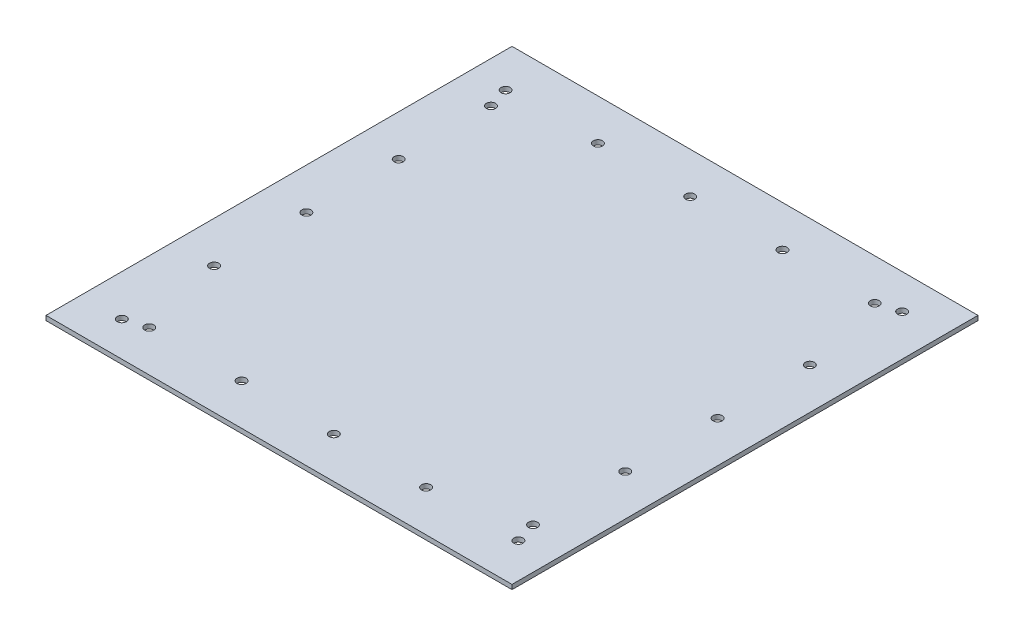
from build123d import *

# Parameters (mm, degrees)
SKETCH1_W           = 510
SKETCH1_H           = 510
BOSS_EXTRUDE1_DEPTH = 5
SKETCH3_R           = 5
CUT_EXTRUDE1_DEPTH  = 6


with BuildPart() as part:
    # Sketch1 → Boss-Extrude1 (new body)
    with BuildSketch(Plane(origin=(0, 0, 0), x_dir=(1, 0, 0), z_dir=(0, 1, 0))):
        Rectangle(SKETCH1_W, SKETCH1_H)
    extrude(amount=BOSS_EXTRUDE1_DEPTH)

    # Sketch3 → Cut-Extrude1 (cut, through all)
    with BuildSketch(Plane.XZ):
        with Locations((217, 210)):
            Circle(SKETCH3_R)
        with Locations((116, 210)):
            Circle(SKETCH3_R)
        with Locations((15, 210)):
            Circle(SKETCH3_R)
        with Locations((-86, 210)):
            Circle(SKETCH3_R)
        with Locations((-187, 210)):
            Circle(SKETCH3_R)
        with Locations((-210, 217)):
            Circle(SKETCH3_R)
        with Locations((-210, 116)):
            Circle(SKETCH3_R)
        with Locations((-210, 15)):
            Circle(SKETCH3_R)
        with Locations((-210, -86)):
            Circle(SKETCH3_R)
        with Locations((-210, -187)):
            Circle(SKETCH3_R)
        with Locations((-217, -210)):
            Circle(SKETCH3_R)
        with Locations((-116, -210)):
            Circle(SKETCH3_R)
        with Locations((-15, -210)):
            Circle(SKETCH3_R)
        with Locations((86, -210)):
            Circle(SKETCH3_R)
        with Locations((187, -210)):
            Circle(SKETCH3_R)
        with Locations((210, -217)):
            Circle(SKETCH3_R)
        with Locations((210, -116)):
            Circle(SKETCH3_R)
        with Locations((210, -15)):
            Circle(SKETCH3_R)
        with Locations((210, 86)):
            Circle(SKETCH3_R)
        with Locations((210, 187)):
            Circle(SKETCH3_R)
    extrude(amount=-CUT_EXTRUDE1_DEPTH, mode=Mode.SUBTRACT)


solid = part.part
